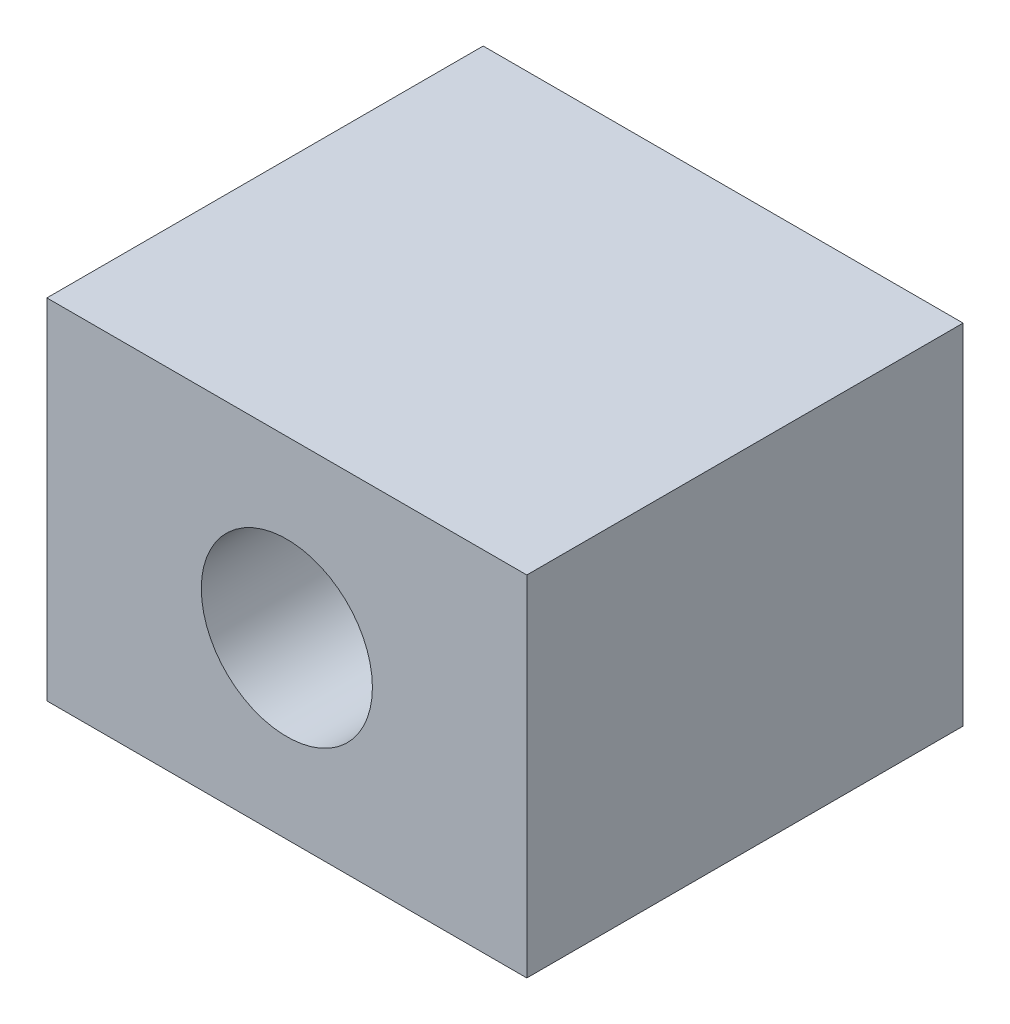
from build123d import *

# Parameters (mm, degrees)
ESQUISSE1_W             = 55
ESQUISSE1_H             = 40
BOSS_EXTRU_1_DEPTH      = 50
ESQUISSE2_R             = 9.804919657
ENL_V_MAT_EXTRU_1_DEPTH = 100


with BuildPart() as part:
    # Esquisse1 → Boss.-Extru.1 (new body)
    with BuildSketch(Plane.XY):
        with Locations((27.5, 20)):
            Rectangle(ESQUISSE1_W, ESQUISSE1_H)
    extrude(amount=BOSS_EXTRU_1_DEPTH)

    # Esquisse2 → Enlèv. mat.-Extru.1 (cut)
    with BuildSketch(Plane.XY.offset(50)):
        with Locations((27.5, 20)):
            Circle(ESQUISSE2_R)
    extrude(amount=-ENL_V_MAT_EXTRU_1_DEPTH, mode=Mode.SUBTRACT)


solid = part.part
